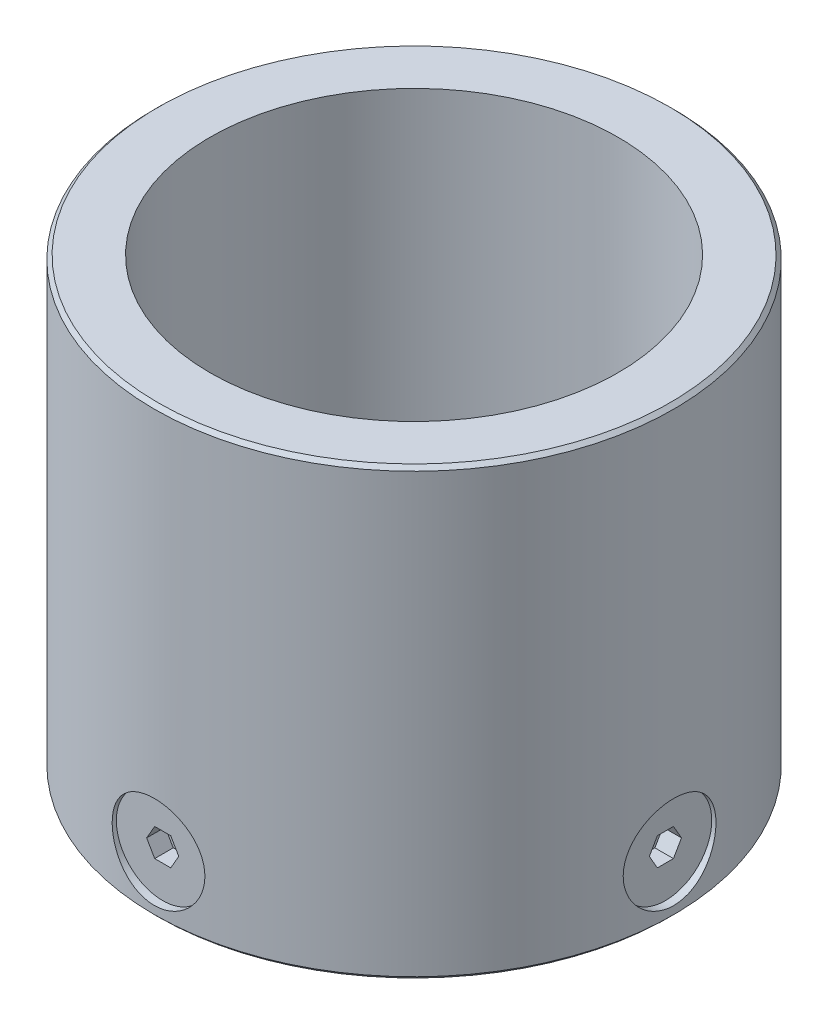
from build123d import *

# Parameters (mm, degrees)
SKETCH_1_R               = 14
SKETCH_1_R_2             = 11
EXTRUDE_1_DEPTH          = 24
CHAMFER_1_SIZE           = 0.2
SKETCH_2_R               = 2.5
CUT_EXTRUDE_1_DEPTH      = 32.112698372
EXTRUDE_START            = 12
SKETCH_2_3_R             = 2.5
EXTRUDE_2_DEPTH          = 1.55
CUT_EXTRUDE_START        = 13.55
CUT_EXTRUDE_2_DEPTH      = 1
PATTERN_CIRCULAR_1_COUNT = 4
PATTERN_CIRCULAR_2_COUNT = 4


with BuildPart() as part:
    # Sketch 1 → Extrude 1 (new body)
    with BuildSketch(Plane(origin=(0, 0, 0), x_dir=(1, 0, 0), z_dir=(0, 1, 0))):
        with Locations(Location((0, 0, 0), (0, 0, 270))):
            Circle(SKETCH_1_R)
        with Locations(Location((0, 0, 0), (0, 0, 270))):
            Circle(SKETCH_1_R_2, mode=Mode.SUBTRACT)
    extrude(amount=EXTRUDE_1_DEPTH)

    # Chamfer 1
    chamfer_1_edges = [part.edges().sort_by_distance(p)[0] for p in [
        (0, 0, -14),
        (0, 24, -14),
    ]]
    chamfer(chamfer_1_edges, length=CHAMFER_1_SIZE)

    # Sketch 2 → Cut-Extrude 1 (cut, through all)
    with BuildSketch(Plane(origin=(0, 0, 0), x_dir=(0, 0, -1), z_dir=(1, 0, 0))):
        with Locations(Location((0, 3.127422807, 0), (0, 0, 180))):
            Circle(SKETCH_2_R)
    cut_extrude_1 = extrude(amount=CUT_EXTRUDE_1_DEPTH, mode=Mode.SUBTRACT)

    # Pattern Circular 1: Cut-Extrude 1 ×4 about axis
    pattern_circular_1_axis = Axis((0, 24, 0), (0, -1, 0))
    for i in range(1, PATTERN_CIRCULAR_1_COUNT):
        add(cut_extrude_1.rotate(pattern_circular_1_axis, i * 360 / PATTERN_CIRCULAR_1_COUNT), mode=Mode.SUBTRACT)


with BuildPart() as body_2:
    # Sketch 2_3 → Extrude 2 (new body)
    with BuildSketch(Plane(origin=(0, 0, 0), x_dir=(0, 0, -1), z_dir=(1, 0, 0)).offset(EXTRUDE_START)):
        with Locations(Location((0, 3.127422807, 0), (0, 0, 180))):
            Circle(SKETCH_2_3_R)
        Polygon((0.433012702, 2.377422807), (0.866025404, 3.127422807), (0.433012702, 3.877422807), (-0.433012702, 3.877422807), (-0.866025404, 3.127422807), (-0.433012702, 2.377422807), align=None, mode=Mode.SUBTRACT)
        Polygon((-0.433012702, 2.377422807), (0.433012702, 2.377422807), (0.866025404, 3.127422807), (0.433012702, 3.877422807), (-0.433012702, 3.877422807), (-0.866025404, 3.127422807), align=None)
    extrude(amount=EXTRUDE_2_DEPTH)

    # Sketch 2_4 → Cut-Extrude 2 (cut)
    with BuildSketch(Plane(origin=(0, 0, 0), x_dir=(0, 0, -1), z_dir=(1, 0, 0)).offset(CUT_EXTRUDE_START)):
        Polygon((-0.433012702, 2.377422807), (0.433012702, 2.377422807), (0.866025404, 3.127422807), (0.433012702, 3.877422807), (-0.433012702, 3.877422807), (-0.866025404, 3.127422807), align=None)
    extrude(amount=-CUT_EXTRUDE_2_DEPTH, mode=Mode.SUBTRACT)


with BuildPart() as pattern_circular_2_1:
    # Pattern Circular 2: pattern copy
    add(body_2.part.rotate(Axis((0, 0, 0), (0, 1, 0)), 1 * 360 / PATTERN_CIRCULAR_2_COUNT))


with BuildPart() as pattern_circular_2_2:
    # Pattern Circular 2: pattern copy
    add(body_2.part.rotate(Axis((0, 0, 0), (0, 1, 0)), 2 * 360 / PATTERN_CIRCULAR_2_COUNT))


with BuildPart() as pattern_circular_2_3:
    # Pattern Circular 2: pattern copy
    add(body_2.part.rotate(Axis((0, 0, 0), (0, 1, 0)), 3 * 360 / PATTERN_CIRCULAR_2_COUNT))


solid = Compound([part.part, body_2.part, pattern_circular_2_1.part, pattern_circular_2_2.part, pattern_circular_2_3.part])
